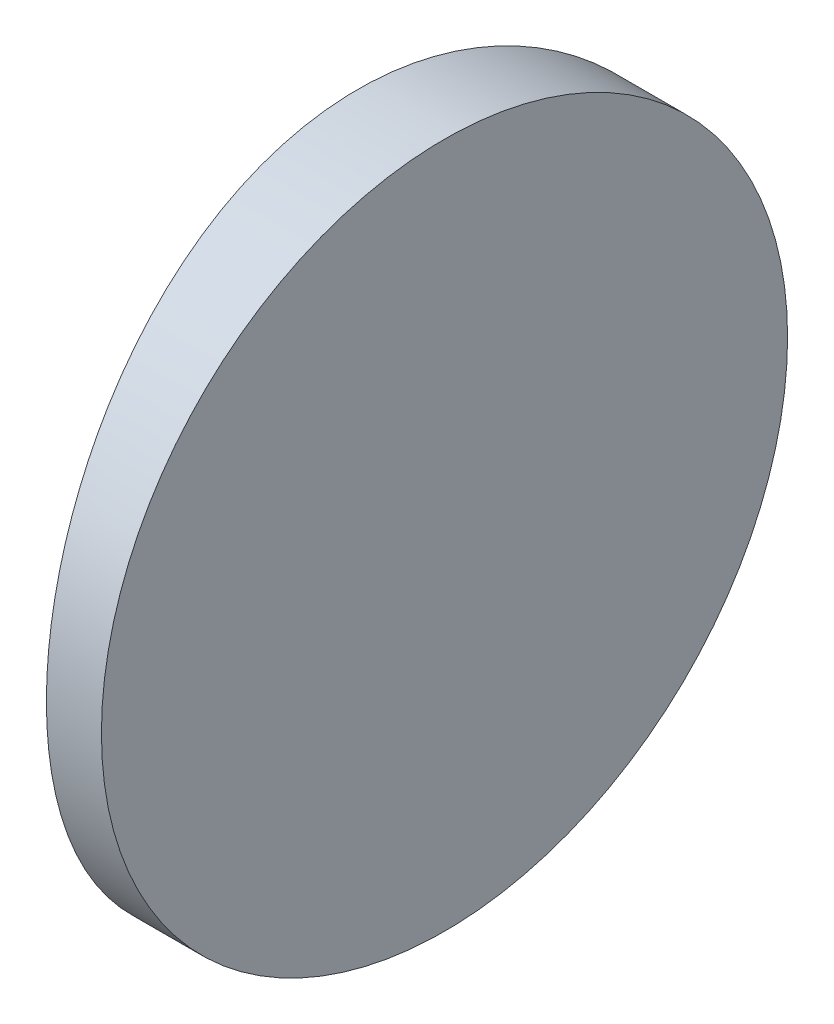
from build123d import *

# Parameters (mm, degrees)
EXTRUDE_1_DEPTH     = 25
CUT_EXTRUDE_8_DEPTH = 12.7


with BuildPart() as part:
    # 草图1 → 凸台-拉伸1 (new body)
    with BuildSketch(Plane(origin=(0, 0, 0), x_dir=(1, 0, 0), z_dir=(0, 1, 0))):
        with BuildLine():
            Line((-63.279390363, 12.5), (-61.274795665, 12.5))
            Line((-61.274795665, 12.5), (-61.274795665, -12.5))
            Line((-61.274795665, -12.5), (-63.279390363, -12.5))
            ThreePointArc((-63.279390363, -12.5), (-64.424795665, 0), (-63.279390363, 12.5))
        make_face()
    extrude(amount=EXTRUDE_1_DEPTH)

    # 草图2 → 切除-拉伸8 (cut)
    with BuildSketch(Plane(origin=(-61.274795665, 0, 0), x_dir=(0, 0, -1), z_dir=(1, 0, 0))):
        with BuildLine():
            Line((-12.5, 25), (-12.5, 12.5))
            ThreePointArc((-12.5, 12.5), (-8.838834765, 21.338834765), (0, 25))
            Line((0, 25), (-12.5, 25))
        make_face()
        with BuildLine():
            ThreePointArc((0, 25), (8.838834765, 21.338834765), (12.5, 12.5))
            Line((12.5, 12.5), (12.5, 25))
            Line((12.5, 25), (0, 25))
        make_face()
        with BuildLine():
            ThreePointArc((12.5, 12.5), (8.838834765, 3.661165235), (0, 0))
            Line((0, 0), (12.5, 0))
            Line((12.5, 0), (12.5, 12.5))
        make_face()
        with BuildLine():
            Line((-12.5, 12.5), (-12.5, 0))
            Line((-12.5, 0), (0, 0))
            ThreePointArc((0, 0), (-8.838834765, 3.661165235), (-12.5, 12.5))
        make_face()
    extrude(amount=-CUT_EXTRUDE_8_DEPTH, mode=Mode.SUBTRACT)


solid = part.part
